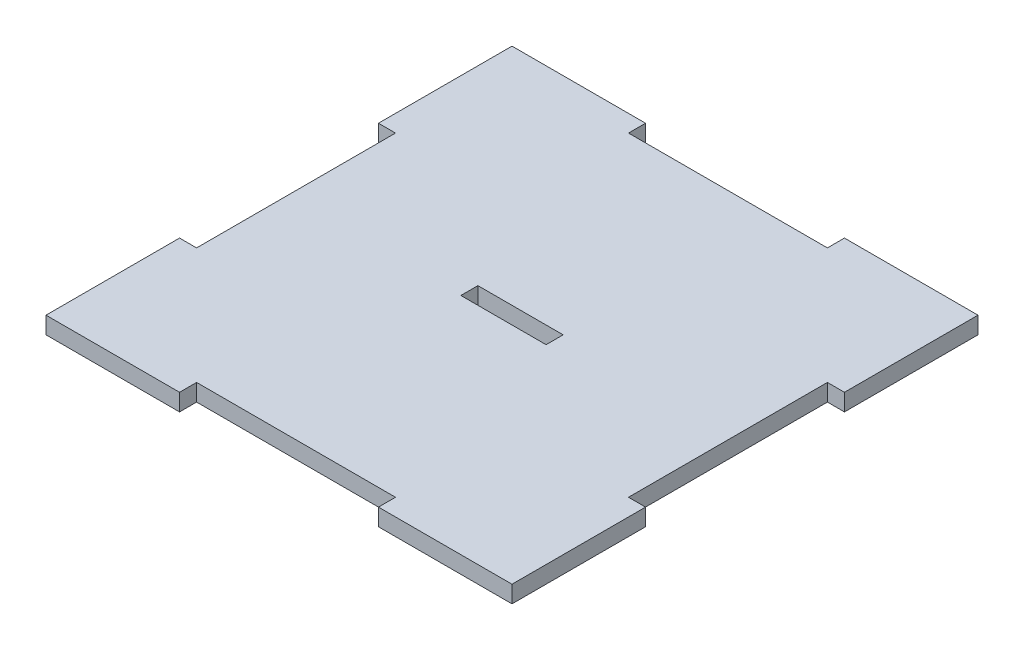
from build123d import *

# Parameters (mm, degrees)
BOSS_EXTRUDE1_DEPTH = 3
SKETCH2_W           = 15
SKETCH2_H           = 3
CUT_EXTRUDE1_DEPTH  = 3


with BuildPart() as part:
    # Sketch1 → Boss-Extrude1 (new body)
    with BuildSketch(Plane(origin=(0, 0, 0), x_dir=(1, 0, 0), z_dir=(0, 1, 0))):
        Polygon((-41, -41), (-17.5, -41), (-17.5, -38), (17.5, -38), (17.5, -41), (41, -41), (41, -17.5), (38, -17.5), (38, 17.5), (41, 17.5), (41, 41), (17.5, 41), (17.5, 38), (-17.5, 38), (-17.5, 41), (-41, 41), (-41, 17.5), (-38, 17.5), (-38, -17.5), (-41, -17.5), align=None)
    extrude(amount=BOSS_EXTRUDE1_DEPTH)

    # Sketch2 → Cut-Extrude1 (cut)
    with BuildSketch(Plane(origin=(0, 3, 0), x_dir=(1, 0, 0), z_dir=(0, 1, 0))):
        Rectangle(SKETCH2_W, SKETCH2_H)
    extrude(amount=-CUT_EXTRUDE1_DEPTH, mode=Mode.SUBTRACT)


solid = part.part
